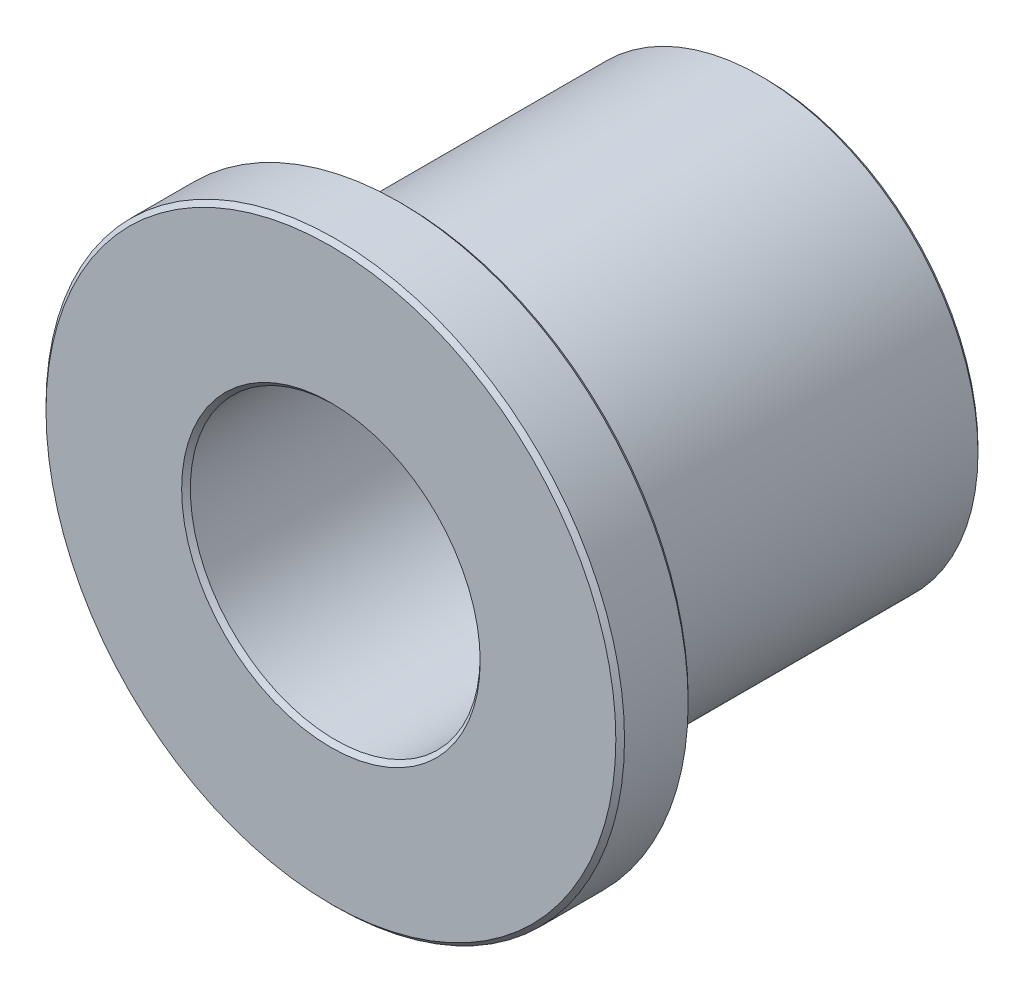
from build123d import *

# Parameters (mm, degrees)
BOSS_EXTRUDE1_START = 9.525
SKETCH3_R           = 12.7
SKETCH3_R_2         = 6.3627
BOSS_EXTRUDE1_DEPTH = 3.175
BOSS_EXTRUDE2_START = 6.35
SKETCH4_R           = 9.5504
SKETCH4_R_2         = 6.3627
BOSS_EXTRUDE2_DEPTH = 15.875
CHAMFER1_SIZE       = 0.190881


with BuildPart() as part:
    # Sketch3 → Boss-Extrude1 (new body)
    with BuildSketch(Plane.XY.offset(BOSS_EXTRUDE1_START)):
        Circle(SKETCH3_R)
        Circle(SKETCH3_R_2, mode=Mode.SUBTRACT)
    extrude(amount=-BOSS_EXTRUDE1_DEPTH)

    # Sketch4 → Boss-Extrude2 (add)
    with BuildSketch(Plane.XY.offset(BOSS_EXTRUDE2_START)):
        Circle(SKETCH4_R)
        Circle(SKETCH4_R_2, mode=Mode.SUBTRACT)
    extrude(amount=-BOSS_EXTRUDE2_DEPTH)

    # Chamfer1
    chamfer1_edges = [part.edges().sort_by_distance(p)[0] for p in [
        (-6.3627, 0, -9.525),
        (-9.5504, 0, 6.35),
        (-12.7, 0, 9.525),
        (-12.7, 0, 6.35),
        (-6.3627, 0, 9.525),
        (-9.5504, 0, -9.525),
    ]]
    chamfer(chamfer1_edges, length=CHAMFER1_SIZE)


solid = part.part
